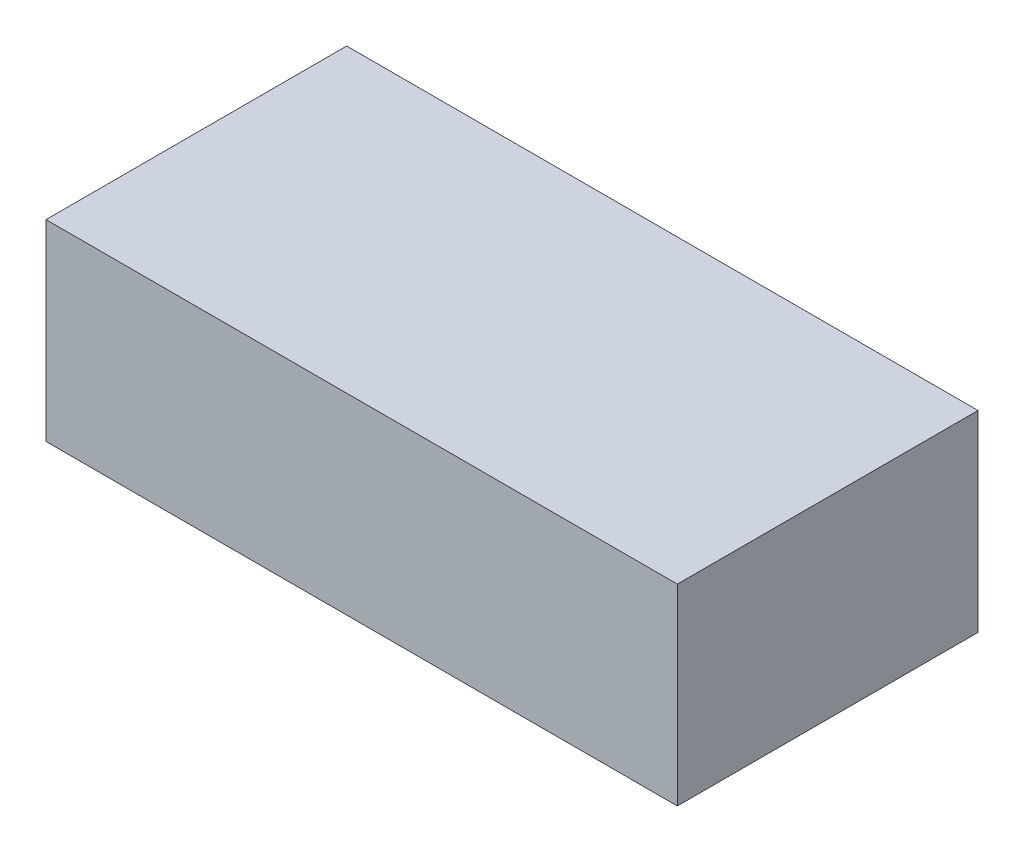
from build123d import *

# Parameters (mm, degrees)
SKETCH1_W           = 80
SKETCH1_H           = 38.1
BOSS_EXTRUDE1_DEPTH = 24.35


with BuildPart() as part:
    # Sketch1 → Boss-Extrude1 (new body)
    with BuildSketch(Plane(origin=(0, 0, 0), x_dir=(1, 0, 0), z_dir=(0, 1, 0))):
        Rectangle(SKETCH1_W, SKETCH1_H)
    extrude(amount=BOSS_EXTRUDE1_DEPTH)


solid = part.part
